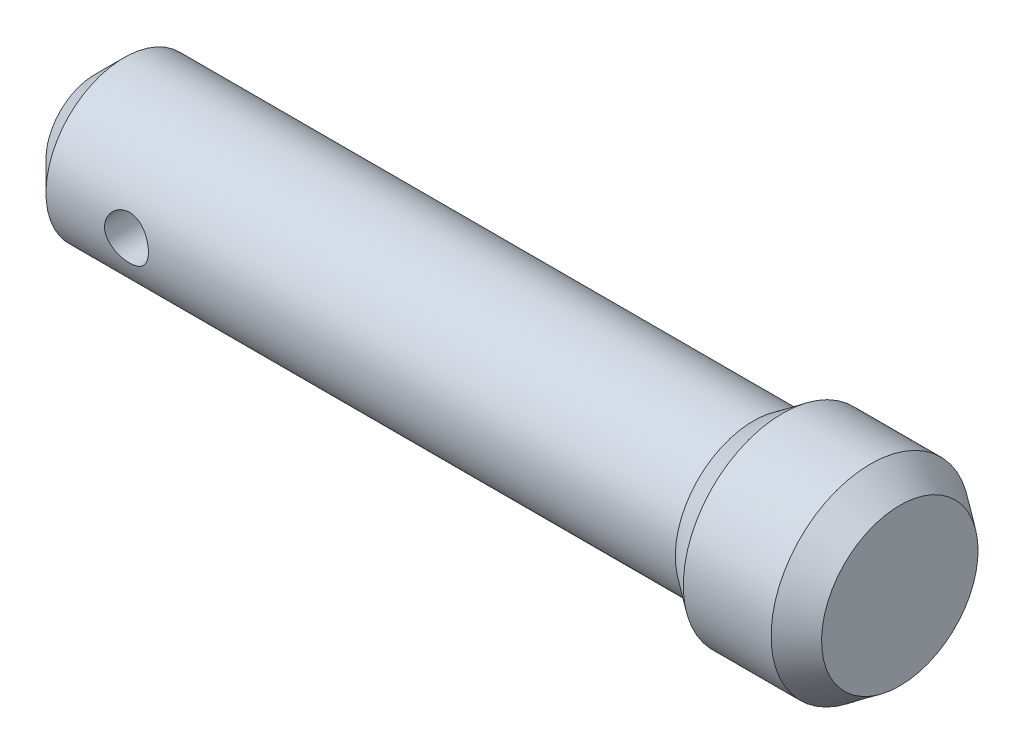
from build123d import *

# Parameters (mm, degrees)
CROQUIS1_W                 = 86
CROQUIS1_H                 = 10.691540382
CROQUIS1_W_2               = 12
CROQUIS1_H_2               = 13.591389859
CROQUIS2_R                 = 3
CORTAR_EXTRUIR1_DEPTH      = 14.591389858
CORTAR_EXTRUIR1_DEPTH_BACK = 14.591389858


with BuildPart() as part:
    # Croquis1 → Revolución3 (revolve)
    with BuildSketch(Plane.XY):
        with Locations((43, -5.345770191)):
            Rectangle(CROQUIS1_W, CROQUIS1_H)
        Polygon((0, -10.691540382), (0, 0), (-4, -4), (-4, -10.691540382), align=None)
        with Locations((96, -3.895845453)):
            Rectangle(CROQUIS1_W_2, CROQUIS1_H_2)
        Polygon((90, 2.899849477), (86, 0), (86, -10.691540382), (90, -10.691540382), align=None)
        Polygon((106, 0), (102, 2.899849477), (102, -10.691540382), (106, -10.691540382), align=None)
    revolve(axis=Axis((-4, -10.691540382, 0), (1, 0, 0)))

    # Croquis2 → Cortar-Extruir1 (cut, two sides)
    with BuildSketch(Plane.XY) as cortar_extruir1_sk:
        with Locations((11, -10.691540382)):
            Circle(CROQUIS2_R)
    extrude(amount=CORTAR_EXTRUIR1_DEPTH, mode=Mode.SUBTRACT)
    extrude(cortar_extruir1_sk.sketch, amount=-CORTAR_EXTRUIR1_DEPTH_BACK, mode=Mode.SUBTRACT)


solid = part.part
